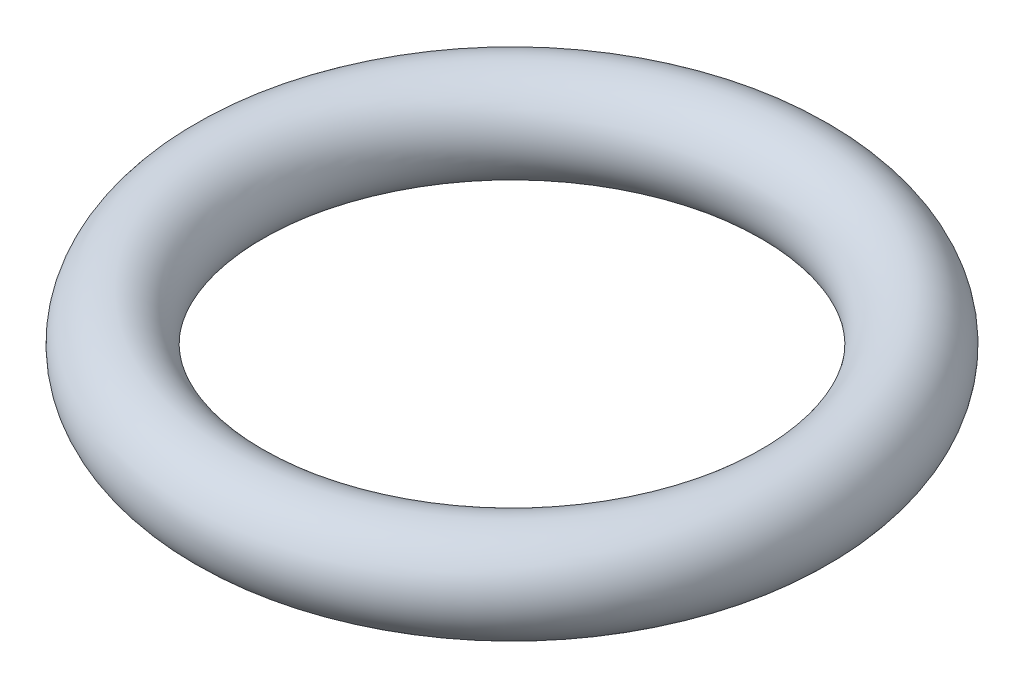
from build123d import *

# Parameters (mm, degrees)
SWEEP1_PROFILE_R = 25.4


with BuildPart() as part:
    # Sweep1: sweep along a path in Sketch1
    with BuildLine(Plane(origin=(0, 0, 0), x_dir=(1, 0, 0), z_dir=(0, 1, 0))) as sweep1_path:
        CenterArc((0, 0), 152.4, 0, 360)
    # Sweep1 profile (on start of the path) → Sweep1 (sweep)
    with BuildSketch(Plane(origin=(152.4, 0, 0), x_dir=(-1, 0, 0), z_dir=(0, 0, -1))):
        Circle(SWEEP1_PROFILE_R)
    sweep(path=sweep1_path.line)


solid = part.part
